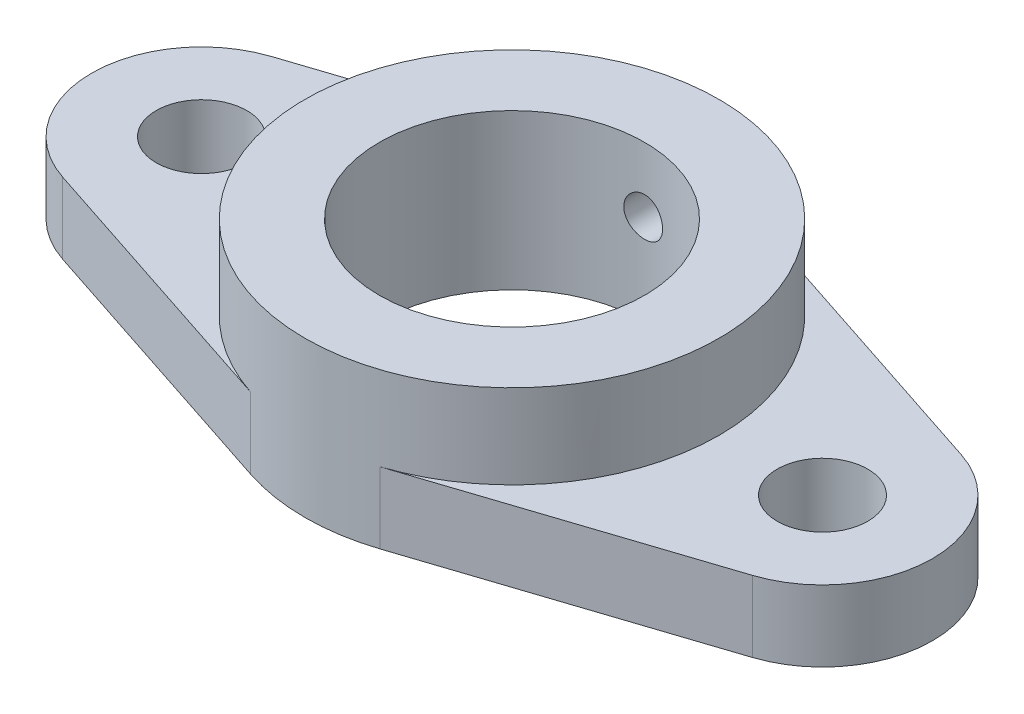
from build123d import *

# Parameters (mm, degrees)
EXTRUDE_2_DEPTH     = 11
SKETCH_2_R          = 7
CUT_EXTRUDE_1_DEPTH = 11
SKETCH_3_R          = 32
EXTRUDE_3_DEPTH     = 24
SKETCH_4_R          = 20.5
CUT_EXTRUDE_2_DEPTH = 25
SKETCH_5_R          = 3
CUT_EXTRUDE_3_DEPTH = 33


with BuildPart() as part:
    # 스케치1 → 보스-돌출2 (new body)
    with BuildSketch(Plane(origin=(0, 0, 0), x_dir=(1, 0, 0), z_dir=(0, 1, 0))):
        with BuildLine():
            Line((-53.3125, 16.148601913), (-10, 30.397368307))
            ThreePointArc((-10, 30.397368307), (0, 32), (10, 30.397368307))
            Line((10, 30.397368307), (53.3125, 16.148601913))
            ThreePointArc((53.3125, 16.148601913), (65, 0), (53.3125, -16.148601913))
            Line((53.3125, -16.148601913), (10, -30.397368307))
            ThreePointArc((10, -30.397368307), (0, -32), (-10, -30.397368307))
            Line((-10, -30.397368307), (-53.3125, -16.148601913))
            ThreePointArc((-53.3125, -16.148601913), (-65, 0), (-53.3125, 16.148601913))
        make_face()
    extrude(amount=EXTRUDE_2_DEPTH)

    # 스케치2 → 컷-돌출1 (cut)
    with BuildSketch(Plane(origin=(0, 0, 0), x_dir=(1, 0, 0), z_dir=(0, 1, 0))):
        with Locations((-48, 0)):
            Circle(SKETCH_2_R)
        with Locations((48, 0)):
            Circle(SKETCH_2_R)
    extrude(amount=CUT_EXTRUDE_1_DEPTH, mode=Mode.SUBTRACT)

    # 스케치3 → 보스-돌출3 (add)
    with BuildSketch(Plane(origin=(0, 0, 0), x_dir=(1, 0, 0), z_dir=(0, 1, 0))):
        Circle(SKETCH_3_R)
    extrude(amount=EXTRUDE_3_DEPTH)

    # 스케치4 → 컷-돌출2 (cut, through all)
    with BuildSketch(Plane(origin=(0, 0, 0), x_dir=(1, 0, 0), z_dir=(0, 1, 0))):
        Circle(SKETCH_4_R)
    extrude(amount=CUT_EXTRUDE_2_DEPTH, mode=Mode.SUBTRACT)

    # 스케치5 → 컷-돌출3 (cut, through all)
    with BuildSketch(Plane.XY):
        with Locations((0, 14)):
            Circle(SKETCH_5_R)
    extrude(amount=-CUT_EXTRUDE_3_DEPTH, mode=Mode.SUBTRACT)


solid = part.part
